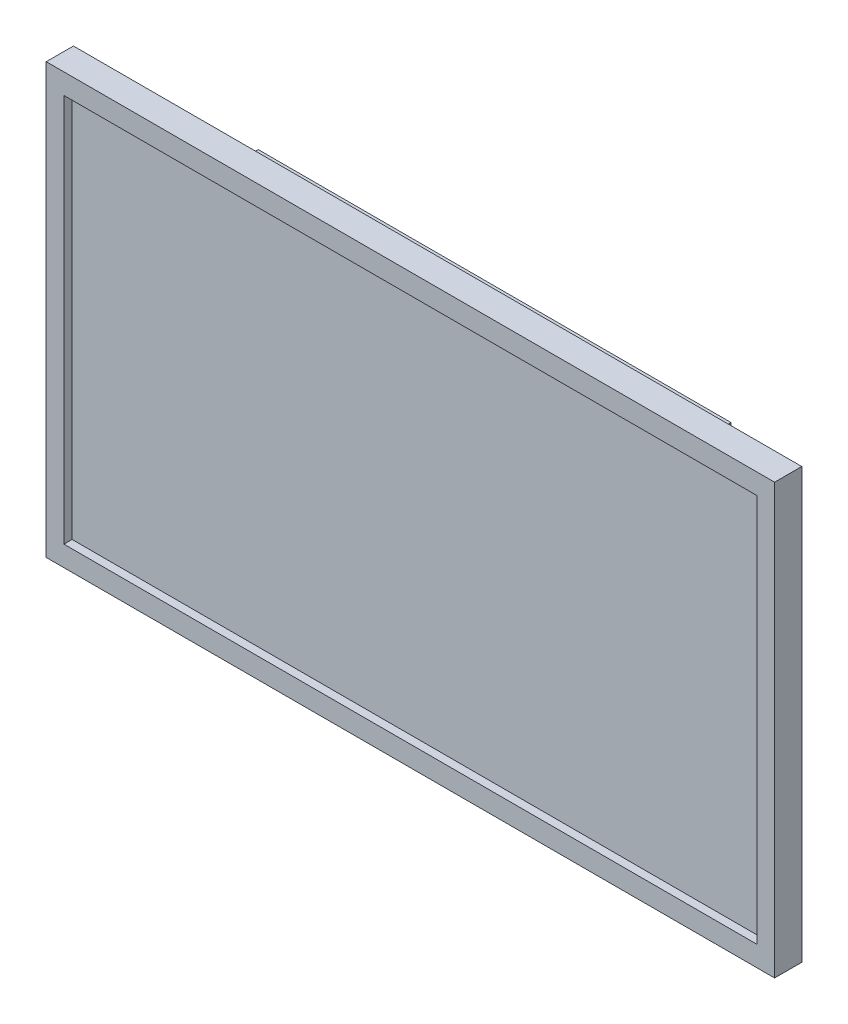
from build123d import *

# Parameters (mm, degrees)
SKETCH_2_W          = 268
SKETCH_2_H          = 158
EXTRUDE_1_DEPTH     = 10
SKETCH_3_W          = 174
SKETCH_3_H          = 118
EXTRUDE_2_DEPTH     = 31
SKETCH_4_W          = 255
SKETCH_4_H          = 143
CUT_EXTRUDE_1_DEPTH = 3


with BuildPart() as part:
    # 草图2 → 凸台-拉伸1 (new body)
    with BuildSketch(Plane.XY):
        Rectangle(SKETCH_2_W, SKETCH_2_H)
    extrude(amount=-EXTRUDE_1_DEPTH)

    # 草图3 → 凸台-拉伸2 (add)
    with BuildSketch(Plane.XY):
        Rectangle(SKETCH_3_W, SKETCH_3_H)
    extrude(amount=-EXTRUDE_2_DEPTH)

    # 草图4 → 切除-拉伸1 (cut)
    with BuildSketch(Plane.XY):
        Rectangle(SKETCH_4_W, SKETCH_4_H)
    extrude(amount=-CUT_EXTRUDE_1_DEPTH, mode=Mode.SUBTRACT)


solid = part.part
